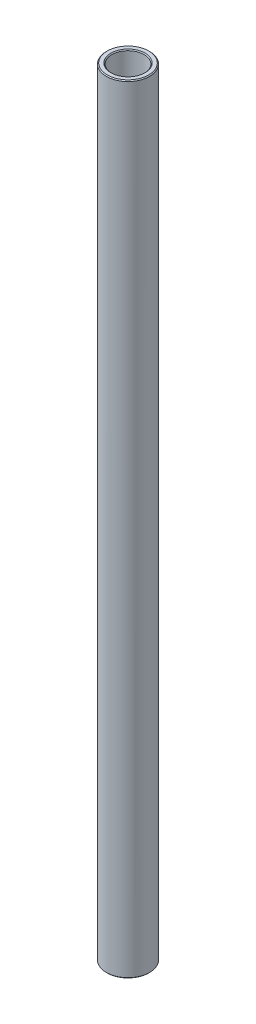
from build123d import *

# Parameters (mm, degrees)
SKETCH1_W     = 1.5875
SKETCH1_H     = 228.6
CHAMFER1_SIZE = 0.254


with BuildPart() as part:
    # Sketch1 → Revolve1 (revolve)
    with BuildSketch(Plane.XY):
        with Locations((5.55625, 0)):
            Rectangle(SKETCH1_W, SKETCH1_H)
    revolve(axis=Axis((0, 11.60859375, 0), (0, -1, 0)))

    # Chamfer1
    chamfer1_edges = [part.edges().sort_by_distance(p)[0] for p in [
        (-4.7625, -114.3, 0),
        (-6.35, -114.3, 0),
        (-6.35, 114.3, 0),
        (-4.7625, 114.3, 0),
    ]]
    chamfer(chamfer1_edges, length=CHAMFER1_SIZE)


solid = part.part
